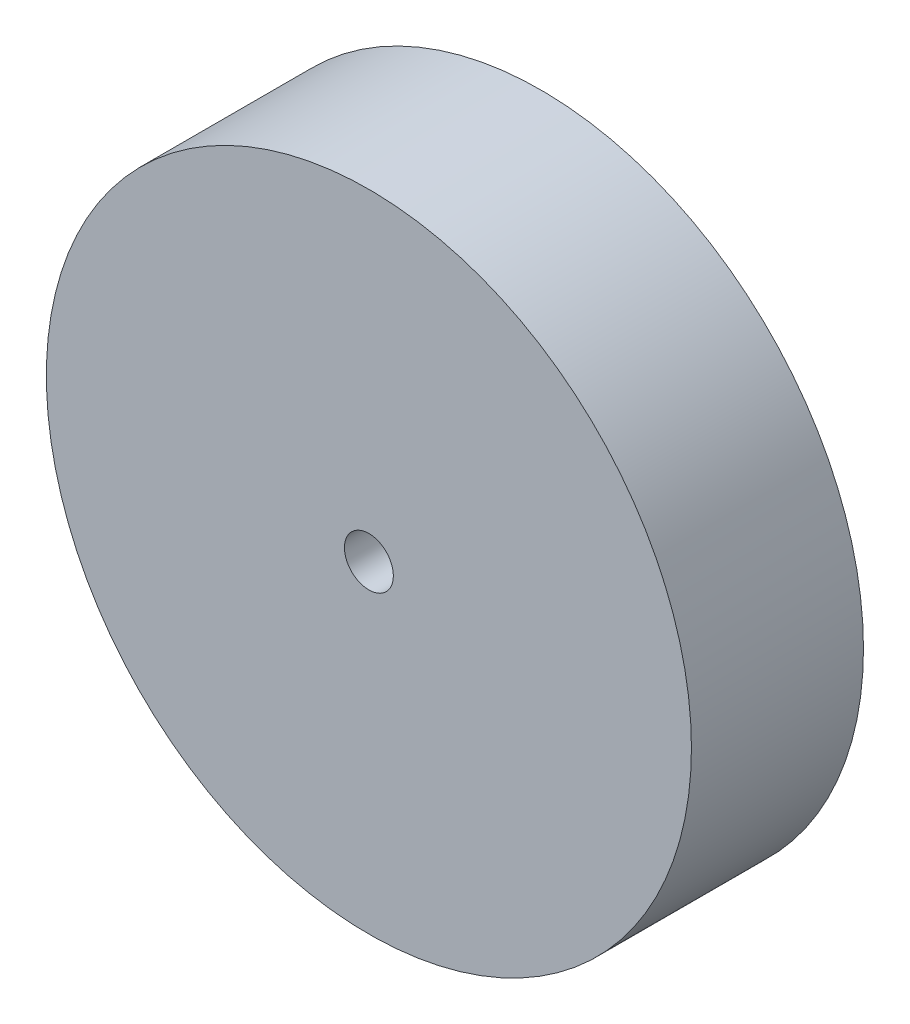
from build123d import *

# Parameters (mm, degrees)
SKETCH1_R           = 75
SKETCH1_R_2         = 5.685874895
BOSS_EXTRUDE1_DEPTH = 40


with BuildPart() as part:
    # Sketch1 → Boss-Extrude1 (new body)
    with BuildSketch(Plane.XY):
        Circle(SKETCH1_R)
        Circle(SKETCH1_R_2, mode=Mode.SUBTRACT)
    extrude(amount=BOSS_EXTRUDE1_DEPTH)


solid = part.part
